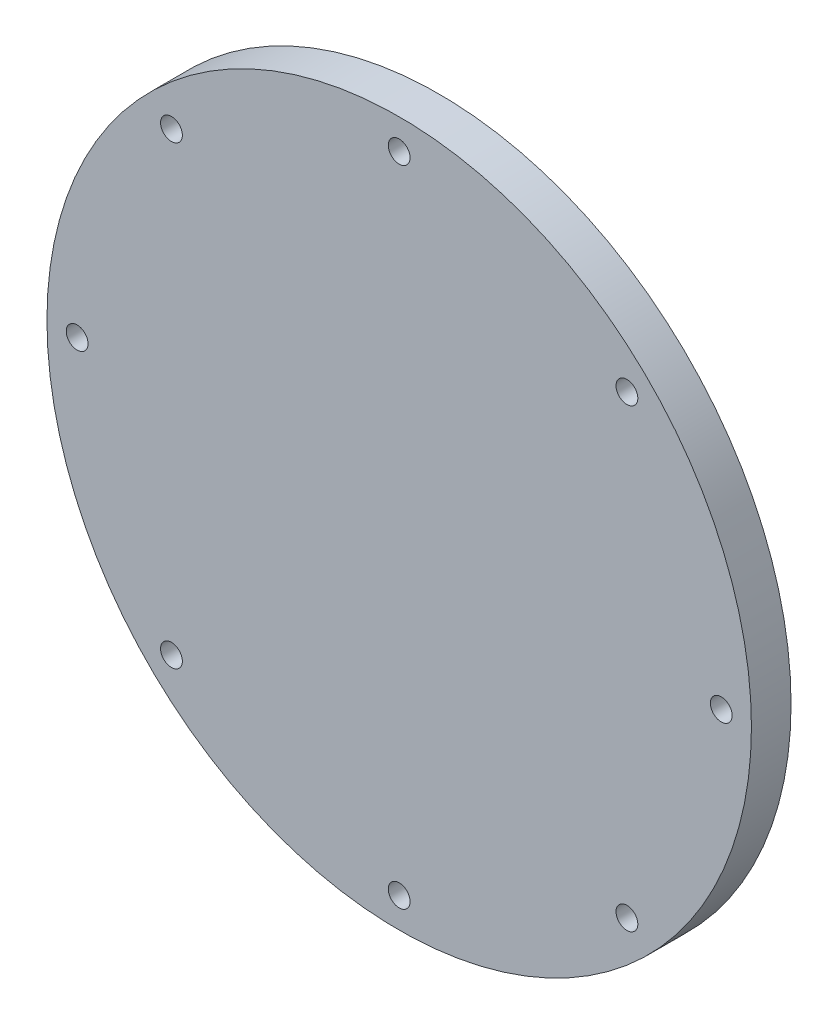
from build123d import *

# Parameters (mm, degrees)
SKETCH2_R           = 88.9
BOSS_EXTRUDE1_DEPTH = 10
SKETCH3_R           = 2.75
CUT_EXTRUDE1_DEPTH  = 11


with BuildPart() as part:
    # Sketch2 → Boss-Extrude1 (new body)
    with BuildSketch(Plane.XY):
        Circle(SKETCH2_R)
    extrude(amount=BOSS_EXTRUDE1_DEPTH)

    # Sketch3 → Cut-Extrude1 (cut, through all)
    with BuildSketch(Plane.XY.offset(10)):
        with Locations((0, 81.28)):
            Circle(SKETCH3_R)
        with Locations((57.473639175, 57.473639175)):
            Circle(SKETCH3_R)
        with Locations((81.28, 0)):
            Circle(SKETCH3_R)
        with Locations((57.473639175, -57.473639175)):
            Circle(SKETCH3_R)
        with Locations((0, -81.28)):
            Circle(SKETCH3_R)
        with Locations((-57.473639175, -57.473639175)):
            Circle(SKETCH3_R)
        with Locations((-81.28, 0)):
            Circle(SKETCH3_R)
        with Locations((-57.473639175, 57.473639175)):
            Circle(SKETCH3_R)
    extrude(amount=-CUT_EXTRUDE1_DEPTH, mode=Mode.SUBTRACT)


solid = part.part
